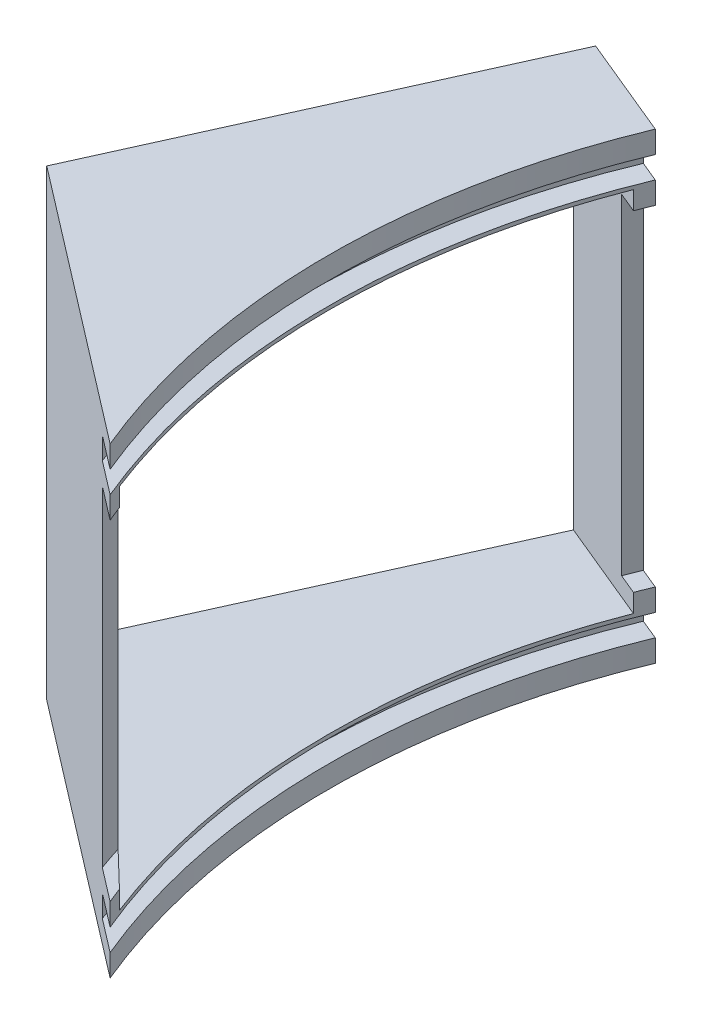
from build123d import *

# Parameters (mm, degrees)
R_VOLUTION1_ANGLE       = 45
ENL_V_MAT_EXTRU_1_DEPTH = 25
ENL_V_MAT_EXTRU_2_DEPTH = 64
ENL_V_MAT_EXTRU_3_DEPTH = 64


with BuildPart() as part:
    # Esquisse1 → Révolution1 (revolve, symmetric)
    with BuildSketch(Plane.XY) as r_volution1_sk:
        Polygon((-127, 31.5), (-97, 31.5), (-97, 28.5), (-100, 28.5), (-100, 25.5), (-97, 25.5), (-97, 22.5), (-100, 22.5), (-100, -22.5), (-97, -22.5), (-97, -25.5), (-100, -25.5), (-100, -28.5), (-97, -28.5), (-97, -31.5), (-127, -31.5), align=None)
    revolve(axis=Axis((0, 55, 0), (0, -1, 0)), revolution_arc=R_VOLUTION1_ANGLE / 2)
    revolve(r_volution1_sk.sketch, axis=Axis((0, 55, 0), (0, 1, 0)), revolution_arc=R_VOLUTION1_ANGLE / 2)

    # Esquisse3 → Enlèv. mat.-Extru.1 (cut, symmetric)
    with BuildSketch(Plane(origin=(0, 0, 0), x_dir=(1, 0, 0), z_dir=(0, 1, 0))):
        Polygon((-127, 50.133100711), (-90.465463023, 35), (-90.465463023, -35), (-127, 0.133100711), align=None)
    extrude(amount=ENL_V_MAT_EXTRU_1_DEPTH, both=True, mode=Mode.SUBTRACT)

    # Esquisse4 → Enlèv. mat.-Extru.2 (cut, through all)
    with BuildSketch(Plane(origin=(0, 31.5, 0), x_dir=(1, 0, 0), z_dir=(0, 1, 0))):
        with BuildLine():
            Line((-117.332700629, -48.60079591), (-89.616314654, -37.120292939))
            Line((-89.616314654, -37.120292939), (-126.704281868, -8.661694766))
            ThreePointArc((-126.704281868, -8.661694766), (-123.641801817, -29.012149926), (-117.332700629, -48.60079591))
        make_face()
    extrude(amount=-ENL_V_MAT_EXTRU_2_DEPTH, mode=Mode.SUBTRACT)

    # Esquisse5 → Enlèv. mat.-Extru.3 (cut, through all)
    with BuildSketch(Plane(origin=(0, 31.5, 0), x_dir=(1, 0, 0), z_dir=(0, 1, 0))):
        Polygon((-126.704281868, -8.661694766), (-148.461378706, 8.033112817), (-117.332700629, 48.60079591), (-103.474507641, 42.860544425), align=None)
    extrude(amount=-ENL_V_MAT_EXTRU_3_DEPTH, mode=Mode.SUBTRACT)


solid = part.part
